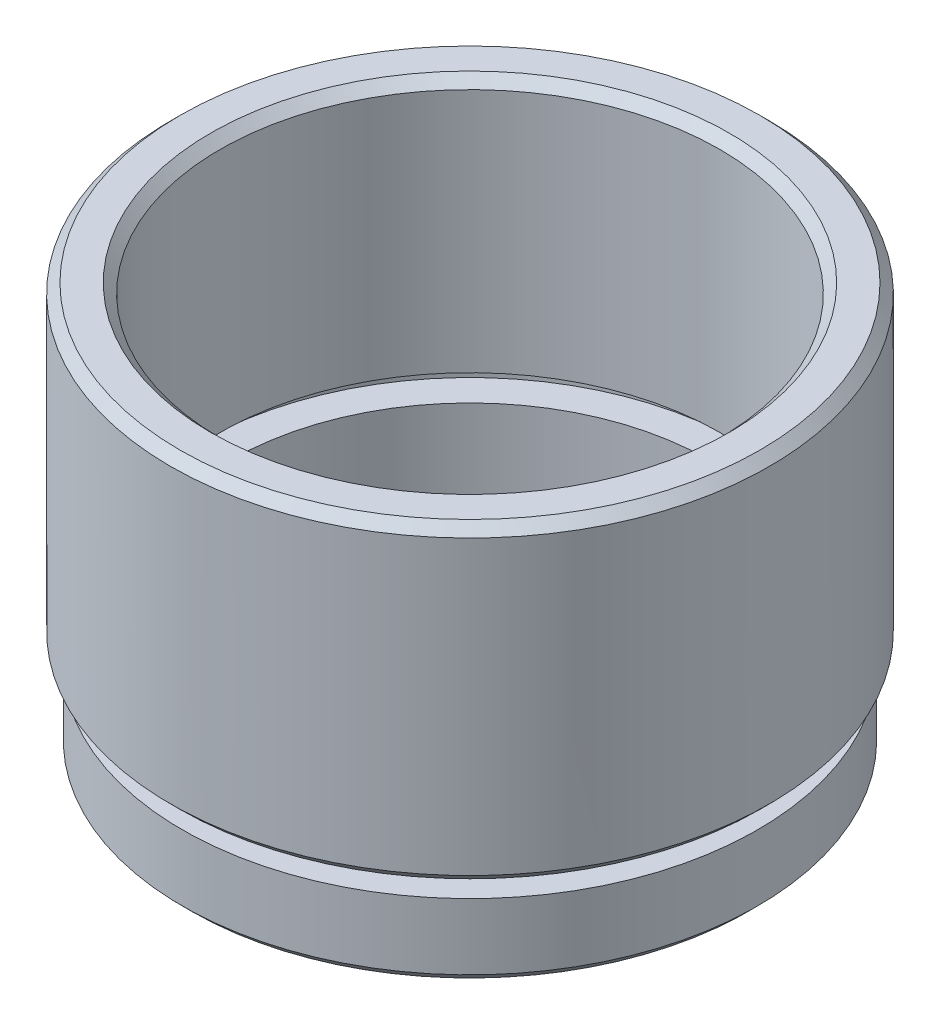
from build123d import *

# Parameters (mm, degrees)
CHAMFER_1_SIZE = 0.5


with BuildPart() as part:
    # 草图1 → 旋转1 (revolve)
    with BuildSketch(Plane.XY, mode=Mode.PRIVATE) as revolve_1_sk:
        Polygon((12, 0), (15.25, 0), (15.25, 4), (13.75, 4), (13.75, 5), (15.875, 5), (15.875, 21.5), (13.25, 21.5), (13.25, 8), (14.35, 8), (14.35, 7), (12.7, 7), (12.7, 2), (12, 2), align=None)
    revolve(revolve_1_sk.sketch.rotate(Axis((0, 0, 0), (0, 1, 0)), 90), axis=Axis((0, 0, 0), (0, 1, 0)))  # turned: the seam where the file's is

    # 倒角1
    chamfer_1_edges = [part.edges().sort_by_distance(p)[0] for p in [
        (0, 21.5, 13.25),
        (0, 21.5, 15.875),
        (0, 5, 15.875),
        (0, 0, 15.25),
    ]]
    chamfer(chamfer_1_edges, length=CHAMFER_1_SIZE)


solid = part.part
